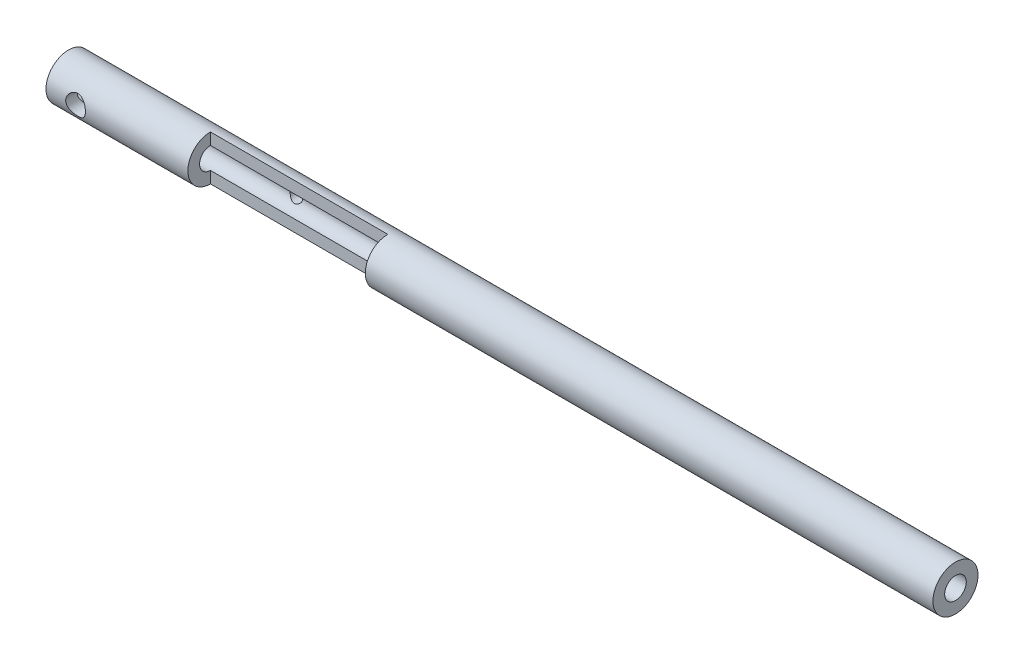
from build123d import *

# Parameters (mm, degrees)
SKETCH1_R                                            = 3.175
SKETCH1_R_2                                          = 1.524
BOSS_EXTRUDE1_DEPTH                                  = 125
F_5_40_HOLE_FOR_SET_SCREW_ATTACHING_SHAFT_DEPTH      = 10
F_5_40_HOLE_FOR_SET_SCREW_ATTACHING_SHAFT_DEPTH_BACK = 10
SKETCH2_R                                            = 1.38938
SKETCH3_W                                            = 25
SKETCH3_H                                            = 14.833516594
CUT_EXTRUDE2_DEPTH                                   = 126.080619107
SKETCH4_R                                            = 0.889
CUT_EXTRUDE3_DEPTH                                   = 3


with BuildPart() as part:
    # Sketch1 → Boss-Extrude1 (new body)
    with BuildSketch(Plane(origin=(0, 0, 0), x_dir=(0, 0, -1), z_dir=(1, 0, 0))):
        Circle(SKETCH1_R)
        Circle(SKETCH1_R_2, mode=Mode.SUBTRACT)
    extrude(amount=BOSS_EXTRUDE1_DEPTH)

    # Sketch2 → 5-40 hole for set screw attaching shaft (cut, two sides: drawn at the far end of the back side and taken through both)
    with BuildSketch(Plane.XY.offset(-F_5_40_HOLE_FOR_SET_SCREW_ATTACHING_SHAFT_DEPTH_BACK)):
        with Locations((4.171703898, 0)):
            Circle(SKETCH2_R)
    extrude(amount=F_5_40_HOLE_FOR_SET_SCREW_ATTACHING_SHAFT_DEPTH + F_5_40_HOLE_FOR_SET_SCREW_ATTACHING_SHAFT_DEPTH_BACK, mode=Mode.SUBTRACT)

    # Sketch3 → Cut-Extrude2 (cut, through all)
    with BuildSketch(Plane.XY):
        with Locations((32.5, -1.779757755)):
            Rectangle(SKETCH3_W, SKETCH3_H)
    extrude(amount=CUT_EXTRUDE2_DEPTH, mode=Mode.SUBTRACT)

    # Sketch4 → Cut-Extrude3 (cut)
    with BuildSketch(Plane.XY):
        with Locations((30.5963642, 0)):
            Circle(SKETCH4_R)
    extrude(amount=-CUT_EXTRUDE3_DEPTH, mode=Mode.SUBTRACT)


solid = part.part
